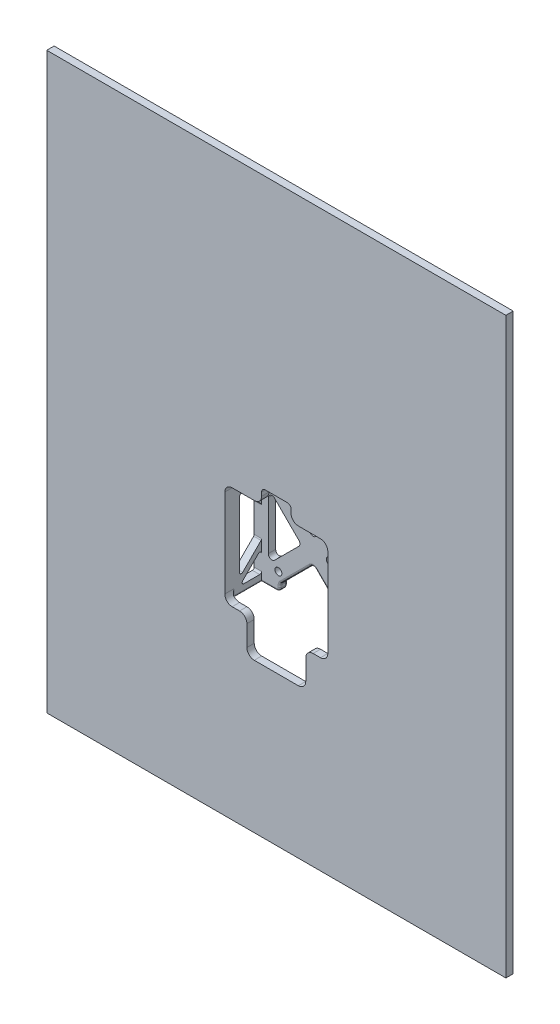
from build123d import *

# Parameters (mm, degrees)
SKETCH1_W           = 198.12
SKETCH1_H           = 247.65
SKETCH1_W_2         = 44.45
SKETCH1_H_2         = 44.45
BOSS_EXTRUDE1_DEPTH = 3.175
FILLET1_R           = 3.175
SKETCH4_R           = 1.5
BOSS_EXTRUDE3_DEPTH = 3.175
BOSS_EXTRUDE4_DEPTH = 15.875
FILLET2_R           = 1.5875
FILLET5_R           = 0.79375
CUT_EXTRUDE1_DEPTH  = 50.8
FILLET6_R           = 0.79375
CUT_EXTRUDE2_REACH  = 5.175
SKETCH8_W           = 25.4
SKETCH8_H           = 15.24
SKETCH8_W_2         = 12.7
SKETCH8_H_2         = 6.35
FILLET7_R           = 3.175
FILLET9_R           = 1.5875


with BuildPart() as part:
    # Sketch1 → Boss-Extrude1 (new body)
    with BuildSketch(Plane.XY):
        Rectangle(SKETCH1_W, SKETCH1_H)
        with Locations((0, -21.9075)):
            Rectangle(SKETCH1_W_2, SKETCH1_H_2, mode=Mode.SUBTRACT)
    extrude(amount=BOSS_EXTRUDE1_DEPTH)

    # Fillet1
    fillet1_edges = [part.edges().sort_by_distance(p)[0] for p in [
        (22.225, -44.1325, 1.5875),
        (22.225, 0.3175, 1.5875),
        (-22.225, 0.3175, 1.5875),
        (-22.225, -44.1325, 1.5875),
    ]]
    fillet(fillet1_edges, radius=FILLET1_R)



with BuildPart() as body_2:
    # Sketch4 → Boss-Extrude3 (new body)
    with BuildSketch(Plane(origin=(0, 0, -12.7), x_dir=(-1, 0, 0), z_dir=(0, 0, -1))):
        Polygon((14.2875, -41.2325), (14.2875, -44.1325), (14.2875, -44.4075), (22.5, -44.4075), (22.5, 0.5925), (-22.5, 0.5925), (-22.5, -44.4075), (-14.2875, -44.4075), (-14.2875, -44.1325), (-14.2875, -41.2325), (0, -26.945), align=None)
        Polygon((19.325, -36.195), (5.0375, -21.9075), (19.325, -7.62), align=None, mode=Mode.SUBTRACT)
        Polygon((14.2875, -2.5825), (0, -16.87), (-14.2875, -2.5825), align=None, mode=Mode.SUBTRACT)
        Polygon((-19.325, -7.62), (-5.0375, -21.9075), (-19.325, -36.195), align=None, mode=Mode.SUBTRACT)
        with Locations((15, -36.9075)):
            Circle(SKETCH4_R, mode=Mode.SUBTRACT)
        with Locations((15, -6.9075)):
            Circle(SKETCH4_R, mode=Mode.SUBTRACT)
        with Locations((-15, -36.9075)):
            Circle(SKETCH4_R, mode=Mode.SUBTRACT)
        with Locations((-15, -6.9075)):
            Circle(SKETCH4_R, mode=Mode.SUBTRACT)
    extrude(amount=BOSS_EXTRUDE3_DEPTH)


with BuildPart() as part_1:
    add(part.part)

    add(body_2.part)  # Boss-Extrude4 merges body 2
    # Sketch2 → Boss-Extrude4 (add)
    with BuildSketch(Plane(origin=(0, 0, 0), x_dir=(-1, 0, 0), z_dir=(0, 0, -1))):
        Polygon((-22.225, -21.9075), (-22.225, -2.8575), (-22.225, 0.5925), (-25.4, 0.5925), (-25.4, -21.9075), align=None)
        Polygon((-22.225, -40.9575), (-22.225, -21.9075), (-25.4, -21.9075), (-25.4, -44.4075), (-22.225, -44.4075), align=None)
        Polygon((25.4, -21.9075), (22.225, -21.9075), (22.225, -40.9575), (22.225, -44.4075), (25.4, -44.4075), align=None)
        Polygon((22.225, 0.5925), (22.225, -2.8575), (22.225, -21.9075), (25.4, -21.9075), (25.4, 0.5925), align=None)
    extrude(amount=BOSS_EXTRUDE4_DEPTH)

    # Fillet2
    fillet2_edges = [part_1.edges().sort_by_distance(p)[0] for p in [
        (-19.325, -36.195, -14.2875),
        (-5.0375, -21.9075, -14.2875),
        (-14.2875, -2.5825, -14.2875),
        (0, -16.87, -14.2875),
        (19.325, -7.62, -14.2875),
        (5.0375, -21.9075, -14.2875),
        (14.2875, -41.2325, -14.2875),
        (0, -26.945, -14.2875),
        (-14.2875, -41.2325, -14.2875),
        (-14.2875, -44.4075, -14.2875),
        (-19.325, -7.62, -14.2875),
        (14.2875, -2.5825, -14.2875),
        (19.325, -36.195, -14.2875),
        (14.2875, -44.4075, -14.2875),
    ]]
    fillet(fillet2_edges, radius=FILLET2_R)

    # Fillet5
    fillet5_edges = [part_1.edges().sort_by_distance(p)[0] for p in [
        (22.225, -1.1325, 0),
        (-22.225, -1.1325, 0),
        (25.4, -21.9075, 0),
        (-25.4, -21.9075, 0),
        (-22.225, -42.6825, 0),
        (25.4, 0.5925, -7.9375),
        (23.8125, 0.5925, 0),
        (22.225, 0.5925, -6.35),
        (0, 0.5925, -12.7),
        (-22.225, 0.5925, -6.35),
        (-23.8125, 0.5925, 0),
        (-25.4, 0.5925, -7.9375),
        (0, 0.5925, -15.875),
        (20.6375, -44.4075, -15.875),
        (-20.6375, -44.4075, -15.875),
        (-23.8125, -44.4075, 0),
        (19.05, -44.4075, -12.7),
        (-19.05, -44.4075, -12.7),
        (-25.4, -21.9075, -15.875),
        (25.4, -21.9075, -15.875),
        (-25.4, -44.4075, -7.9375),
        (-22.225, -44.4075, -6.35),
        (14.752467985, -43.942532015, -15.875),
        (14.752467985, -43.942532015, -12.7),
        (14.2875, -42.355032015, -15.875),
        (14.2875, -42.355032015, -12.7),
        (14.166658758, -41.282554081, -15.875),
        (14.166658758, -41.282554081, -12.7),
        (7.472532015, -34.417532015, -15.875),
        (7.472532015, -34.417532015, -12.7),
        (0, -27.60256403, -15.875),
        (0, -27.60256403, -12.7),
        (-7.472532015, -34.417532015, -12.7),
        (-7.472532015, -34.417532015, -15.875),
        (-14.166658758, -41.282554081, -15.875),
        (-14.166658758, -41.282554081, -12.7),
        (-14.2875, -42.355032015, -12.7),
        (-14.2875, -42.355032015, -15.875),
        (-14.752467985, -43.942532015, -15.875),
        (-14.752467985, -43.942532015, -12.7),
    ]]
    fillet(fillet5_edges, radius=FILLET5_R)

    # Sketch6 → Cut-Extrude1 (cut)
    with BuildSketch(Plane(origin=(25.4, 0, 0), x_dir=(0, 0, -1), z_dir=(1, 0, 0))):
        Polygon((3.175, -2.5825), (12.7, -12.1075), (12.7, -2.5825), align=None)
        Polygon((3.175, -21.9075), (12.7, -21.9075), (12.7, -15.2825), (3.175, -5.7575), align=None)
        Polygon((12.7, -28.5325), (12.7, -21.9075), (3.175, -21.9075), (3.175, -38.0575), align=None)
        Polygon((12.7, -41.2325), (12.7, -31.7075), (3.175, -41.2325), align=None)
    extrude(amount=-CUT_EXTRUDE1_DEPTH, mode=Mode.SUBTRACT)

    # Fillet6
    fillet6_edges = [part_1.edges().sort_by_distance(p)[0] for p in [
        (23.8125, -5.7575, -3.175),
        (23.8125, -38.0575, -3.175),
        (23.8125, -15.2825, -12.7),
        (-23.8125, -15.2825, -12.7),
        (23.8125, -28.5325, -12.7),
        (-23.8125, -5.7575, -3.175),
        (-23.8125, -28.5325, -12.7),
        (-23.8125, -38.0575, -3.175),
        (23.8125, -41.2325, -3.175),
        (-23.8125, -31.7075, -12.7),
        (23.8125, -41.2325, -12.7),
        (23.8125, -31.7075, -12.7),
        (-23.8125, -41.2325, -12.7),
        (-23.8125, -41.2325, -3.175),
        (23.8125, -2.5825, -3.175),
        (23.8125, -12.1075, -12.7),
        (-23.8125, -2.5825, -12.7),
        (23.8125, -2.5825, -12.7),
        (-23.8125, -2.5825, -3.175),
        (-23.8125, -12.1075, -12.7),
    ]]
    fillet(fillet6_edges, radius=FILLET6_R)

    # Sketch8 → Cut-Extrude2 (cut, up to next)
    with BuildSketch(Plane(origin=(0, 0, 0), x_dir=(-1, 0, 0), z_dir=(0, 0, -1)), mode=Mode.PRIVATE) as cut_extrude2_sk1:
        with Locations((0, -51.7525)):
            Rectangle(SKETCH8_W, SKETCH8_H)
    cut_extrude2_tool1 = extrude(cut_extrude2_sk1.sketch, amount=-CUT_EXTRUDE2_REACH, mode=Mode.PRIVATE) & part_1.part
    add(cut_extrude2_tool1.solids().sort_by_distance((0, -51.7525, 0))[0], mode=Mode.SUBTRACT)
    # Sketch8 → Cut-Extrude2 (cut, up to next)
    with BuildSketch(Plane(origin=(0, 0, 0), x_dir=(-1, 0, 0), z_dir=(0, 0, -1)), mode=Mode.PRIVATE) as cut_extrude2_sk2:
        with Locations((0, 3.4925)):
            Rectangle(SKETCH8_W_2, SKETCH8_H_2)
    cut_extrude2_tool2 = extrude(cut_extrude2_sk2.sketch, amount=-CUT_EXTRUDE2_REACH, mode=Mode.PRIVATE) & part_1.part
    add(cut_extrude2_tool2.solids().sort_by_distance((0, 3.4925, 0))[0], mode=Mode.SUBTRACT)

    # Fillet7
    fillet7_edges = [part_1.edges().sort_by_distance(p)[0] for p in [
        (12.7, -44.1325, 1.5875),
        (-12.7, -44.1325, 1.5875),
        (-12.7, -59.3725, 1.5875),
        (12.7, -59.3725, 1.5875),
        (-6.35, 0.3175, 1.5875),
        (6.35, 0.3175, 1.5875),
    ]]
    fillet(fillet7_edges, radius=FILLET7_R)

    # Fillet9
    fillet9_edges = [part_1.edges().sort_by_distance(p)[0] for p in [
        (6.35, 6.6675, 1.5875),
        (-6.35, 6.6675, 1.5875),
    ]]
    fillet(fillet9_edges, radius=FILLET9_R)


solid = part_1.part
